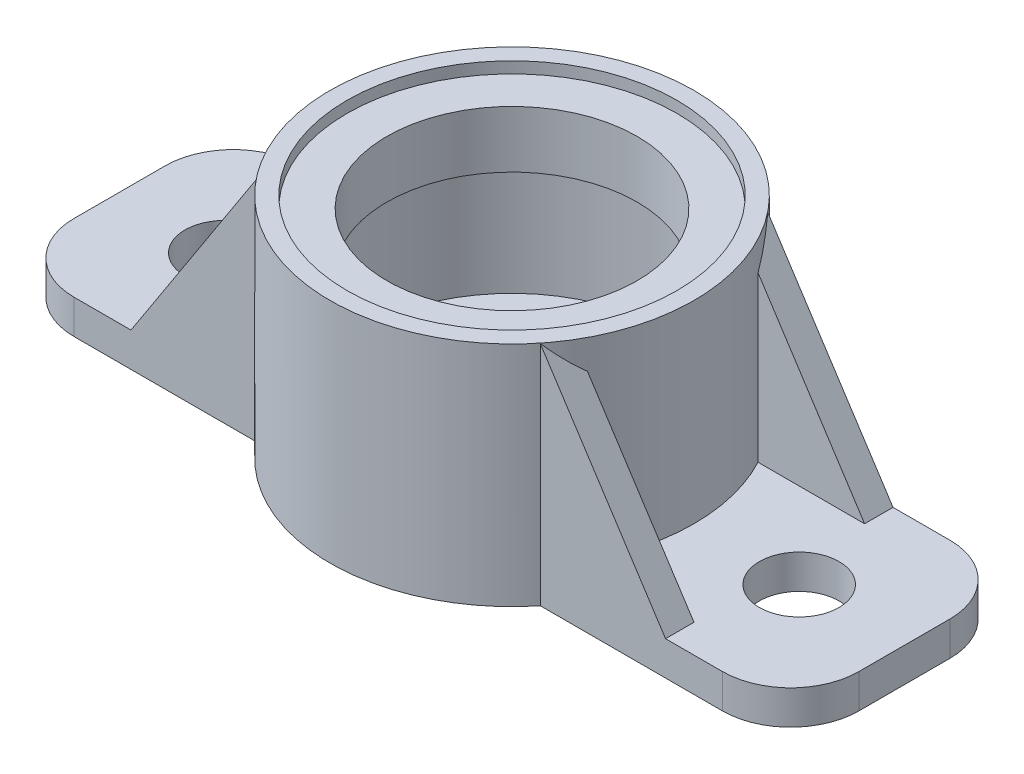
from build123d import *

# Parameters (mm, degrees)
SKETCH2_W           = 350.52
SKETCH2_H           = 101.6
SKETCH2_R           = 43.18
SKETCH2_R_2         = 17.78
BOSS_EXTRUDE1_DEPTH = 15.24
SKETCH2_3_R         = 43.18
SKETCH2_3_R_2       = 20.32
BOSS_EXTRUDE2_DEPTH = 10.16
BOSS_EXTRUDE3_START = -50.8
BOSS_EXTRUDE3_DEPTH = 12.7
BOSS_EXTRUDE4_START = 50.8
BOSS_EXTRUDE4_DEPTH = 12.7
FILLET1_R           = 30.48


with BuildPart() as part:
    # Sketch2 → Boss-Extrude1 (new body)
    with BuildSketch(Plane(origin=(0, 0, 0), x_dir=(1, 0, 0), z_dir=(0, 1, 0))):
        Rectangle(SKETCH2_W, SKETCH2_H)
        Circle(SKETCH2_R, mode=Mode.SUBTRACT)
        with Locations((128.27, 0)):
            Circle(SKETCH2_R_2, mode=Mode.SUBTRACT)
        with Locations((-128.27, 0)):
            Circle(SKETCH2_R_2, mode=Mode.SUBTRACT)
    extrude(amount=BOSS_EXTRUDE1_DEPTH)

    # Sketch2_3 → Boss-Extrude2 (add)
    with BuildSketch(Plane(origin=(0, 0, 0), x_dir=(1, 0, 0), z_dir=(0, 1, 0))):
        Circle(SKETCH2_3_R)
        Circle(SKETCH2_3_R_2, mode=Mode.SUBTRACT)
    extrude(amount=BOSS_EXTRUDE2_DEPTH)

    # Sketch3 → Revolve1 (revolve)
    with BuildSketch(Plane.XY):
        Polygon((43.18, 15.24), (43.18, 0), (81.28, 0), (81.28, 101.6), (73.66, 101.6), (73.66, 96.52), (55.88, 96.52), (55.88, 71.12), (68.58, 71.12), (68.58, 15.24), align=None)
    revolve(axis=Axis((0, 0, 0), (0, 1, 0)))

    # Sketch4 → Boss-Extrude3 (add)
    with BuildSketch(Plane.XY.offset(BOSS_EXTRUDE3_START)):
        Polygon((119.38, 15.24), (63.297160251, 101.6), (63.297160251, 15.24), align=None)
        Polygon((-63.297160251, 15.24), (-119.38, 15.24), (-63.297160251, 101.6), align=None)
    extrude(amount=BOSS_EXTRUDE3_DEPTH)

    # Sketch4_2 → Boss-Extrude4 (add)
    with BuildSketch(Plane.XY.offset(BOSS_EXTRUDE4_START)):
        Polygon((119.38, 15.24), (63.297160251, 101.6), (63.297160251, 15.24), align=None)
        Polygon((-63.297160251, 15.24), (-119.38, 15.24), (-63.297160251, 101.6), align=None)
    extrude(amount=-BOSS_EXTRUDE4_DEPTH)

    # Fillet1
    fillet1_edges = [part.edges().sort_by_distance(p)[0] for p in [
        (-175.26, 7.62, 50.8),
        (-175.26, 7.62, -50.8),
        (175.26, 7.62, -50.8),
        (175.26, 7.62, 50.8),
    ]]
    fillet(fillet1_edges, radius=FILLET1_R)


solid = part.part
